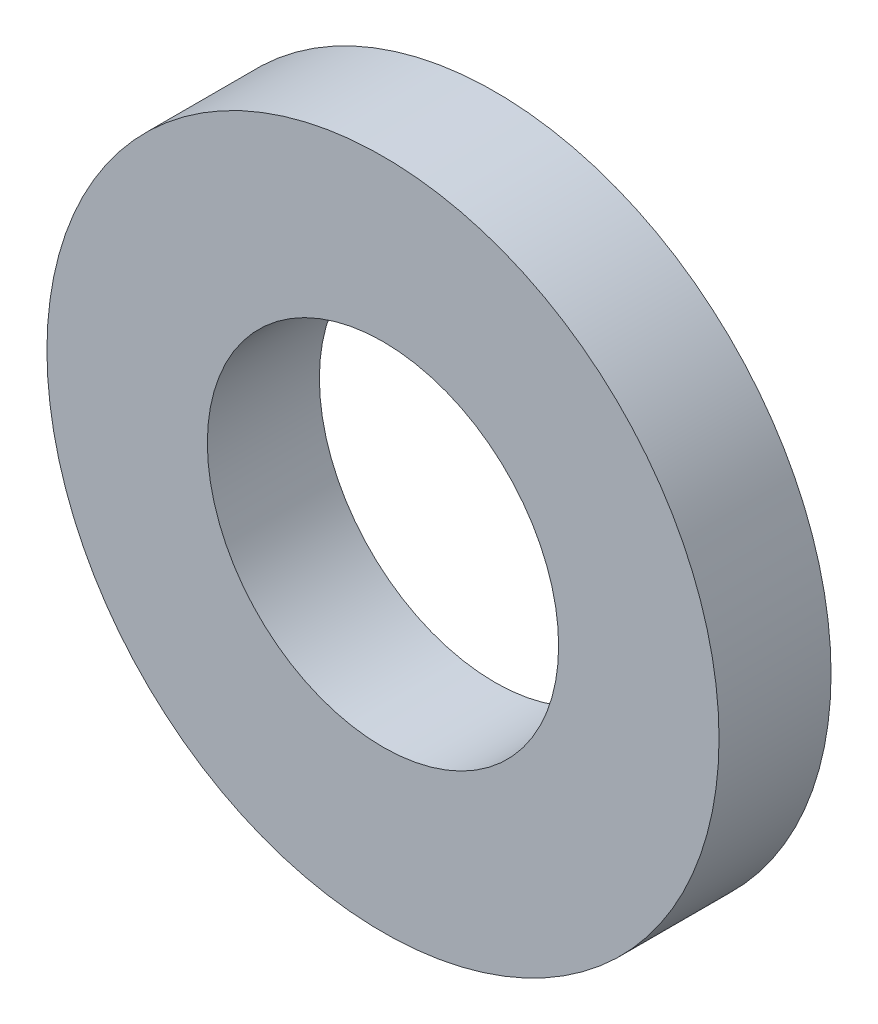
from build123d import *

# Parameters (mm, degrees)
SKETCH1_R           = 9.525
BOSS_EXTRUDE1_DEPTH = 3.175
SKETCH2_R           = 4.7625
BOSS_EXTRUDE2_DEPTH = 4.7498
SKETCH3_R           = 4.9784
CUT_EXTRUDE1_DEPTH  = 7.9756


with BuildPart() as part:
    # Sketch1 → Boss-Extrude1 (new body)
    with BuildSketch(Plane.XY):
        Circle(SKETCH1_R)
    extrude(amount=BOSS_EXTRUDE1_DEPTH)

    # Sketch2 → Boss-Extrude2 (add)
    with BuildSketch(Plane.XY.offset(3.175)):
        Circle(SKETCH2_R)
    extrude(amount=BOSS_EXTRUDE2_DEPTH)

    # Sketch3 → Cut-Extrude1 (cut)
    with BuildSketch(Plane.XY.offset(7.9248)):
        Circle(SKETCH3_R)
    extrude(amount=-CUT_EXTRUDE1_DEPTH, mode=Mode.SUBTRACT)


solid = part.part
